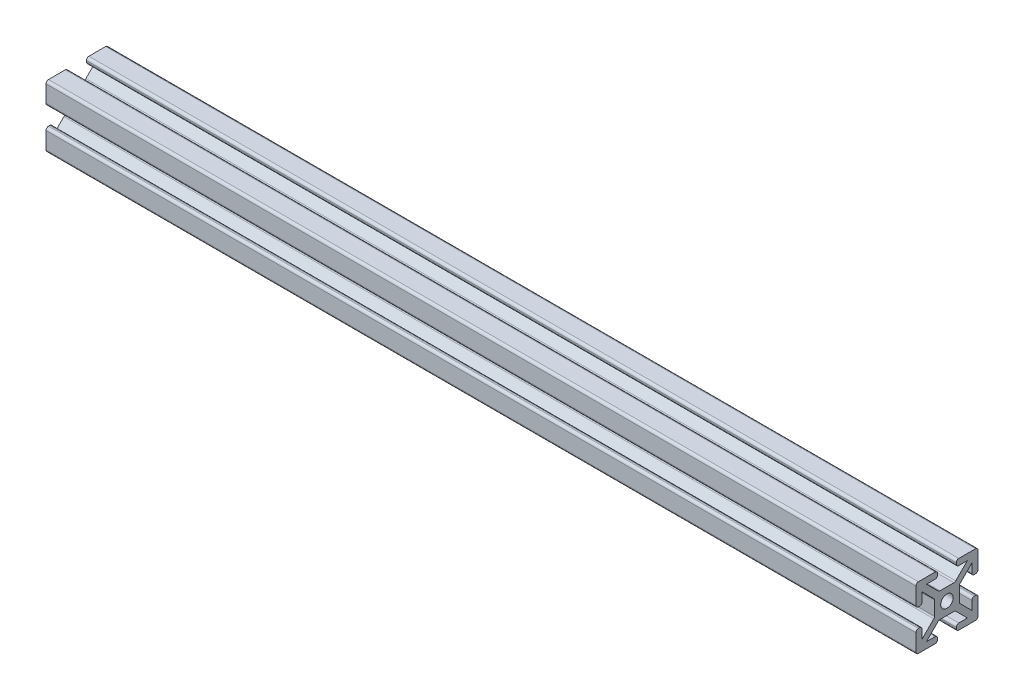
from build123d import *

# Parameters (mm, degrees)
SKETCH11_R       = 2
SIZE_4X4_1_DEPTH = 280


with BuildPart() as part:
    # Sketch11 → Size 4X4 (1) (new body)
    with BuildSketch(Plane(origin=(0, 0, 0), x_dir=(0, 0, -1), z_dir=(1, 0, 0))):
        with BuildLine():
            Line((-3, 9.2), (-3, 8.8))
            ThreePointArc((-3, 8.8), (-3.234314575, 8.234314575), (-3.8, 8))
            Line((-3.8, 8), (-6.585786438, 8))
            Line((-6.585786438, 8), (-2.820101013, 4.234314575))
            ThreePointArc((-2.820101013, 4.234314575), (-2.560562334, 4.060896374), (-2.254415588, 4))
            Line((-2.254415588, 4), (2.254415588, 4))
            ThreePointArc((2.254415588, 4), (2.560562334, 4.060896374), (2.820101013, 4.234314575))
            Line((2.820101013, 4.234314575), (6.585786438, 8))
            Line((6.585786438, 8), (3.8, 8))
            ThreePointArc((3.8, 8), (3.234314575, 8.234314575), (3, 8.8))
            Line((3, 8.8), (3, 9.2))
            ThreePointArc((3, 9.2), (3.234314575, 9.765685425), (3.8, 10))
            Line((3.8, 10), (9.2, 10))
            ThreePointArc((9.2, 10), (9.765685425, 9.765685425), (10, 9.2))
            Line((10, 9.2), (10, 3.8))
            ThreePointArc((10, 3.8), (9.765685425, 3.234314575), (9.2, 3))
            Line((9.2, 3), (8.8, 3))
            ThreePointArc((8.8, 3), (8.234314575, 3.234314575), (8, 3.8))
            Line((8, 3.8), (8, 6.585786438))
            Line((8, 6.585786438), (4.234314575, 2.820101013))
            ThreePointArc((4.234314575, 2.820101013), (4.060896374, 2.560562334), (4, 2.254415588))
            Line((4, 2.254415588), (4, -2.254415588))
            ThreePointArc((4, -2.254415588), (4.060896374, -2.560562334), (4.234314575, -2.820101013))
            Line((4.234314575, -2.820101013), (8, -6.585786438))
            Line((8, -6.585786438), (8, -3.8))
            ThreePointArc((8, -3.8), (8.234314575, -3.234314575), (8.8, -3))
            Line((8.8, -3), (9.2, -3))
            ThreePointArc((9.2, -3), (9.765685425, -3.234314575), (10, -3.8))
            Line((10, -3.8), (10, -9.2))
            ThreePointArc((10, -9.2), (9.765685425, -9.765685425), (9.2, -10))
            Line((9.2, -10), (3.8, -10))
            ThreePointArc((3.8, -10), (3.234314575, -9.765685425), (3, -9.2))
            Line((3, -9.2), (3, -8.8))
            ThreePointArc((3, -8.8), (3.234314575, -8.234314575), (3.8, -8))
            Line((3.8, -8), (6.585786438, -8))
            Line((6.585786438, -8), (2.820101013, -4.234314575))
            ThreePointArc((2.820101013, -4.234314575), (2.560562334, -4.060896374), (2.254415588, -4))
            Line((2.254415588, -4), (-2.254415588, -4))
            ThreePointArc((-2.254415588, -4), (-2.560562334, -4.060896374), (-2.820101013, -4.234314575))
            Line((-2.820101013, -4.234314575), (-6.585786438, -8))
            Line((-6.585786438, -8), (-3.8, -8))
            ThreePointArc((-3.8, -8), (-3.234314575, -8.234314575), (-3, -8.8))
            Line((-3, -8.8), (-3, -9.2))
            ThreePointArc((-3, -9.2), (-3.234314575, -9.765685425), (-3.8, -10))
            Line((-3.8, -10), (-9.2, -10))
            ThreePointArc((-9.2, -10), (-9.765685425, -9.765685425), (-10, -9.2))
            Line((-10, -9.2), (-10, -3.8))
            ThreePointArc((-10, -3.8), (-9.765685425, -3.234314575), (-9.2, -3))
            Line((-9.2, -3), (-8.8, -3))
            ThreePointArc((-8.8, -3), (-8.234314575, -3.234314575), (-8, -3.8))
            Line((-8, -3.8), (-8, -6.585786438))
            Line((-8, -6.585786438), (-4.234314575, -2.820101013))
            ThreePointArc((-4.234314575, -2.820101013), (-4.060896374, -2.560562334), (-4, -2.254415588))
            Line((-4, -2.254415588), (-4, 2.254415588))
            ThreePointArc((-4, 2.254415588), (-4.060896374, 2.560562334), (-4.234314575, 2.820101013))
            Line((-4.234314575, 2.820101013), (-8, 6.585786438))
            Line((-8, 6.585786438), (-8, 3.8))
            ThreePointArc((-8, 3.8), (-8.234314575, 3.234314575), (-8.8, 3))
            Line((-8.8, 3), (-9.2, 3))
            ThreePointArc((-9.2, 3), (-9.765685425, 3.234314575), (-10, 3.8))
            Line((-10, 3.8), (-10, 9.2))
            ThreePointArc((-10, 9.2), (-9.765685425, 9.765685425), (-9.2, 10))
            Line((-9.2, 10), (-3.8, 10))
            ThreePointArc((-3.8, 10), (-3.234314575, 9.765685425), (-3, 9.2))
        make_face()
        Circle(SKETCH11_R, mode=Mode.SUBTRACT)
    extrude(amount=SIZE_4X4_1_DEPTH)


solid = part.part
